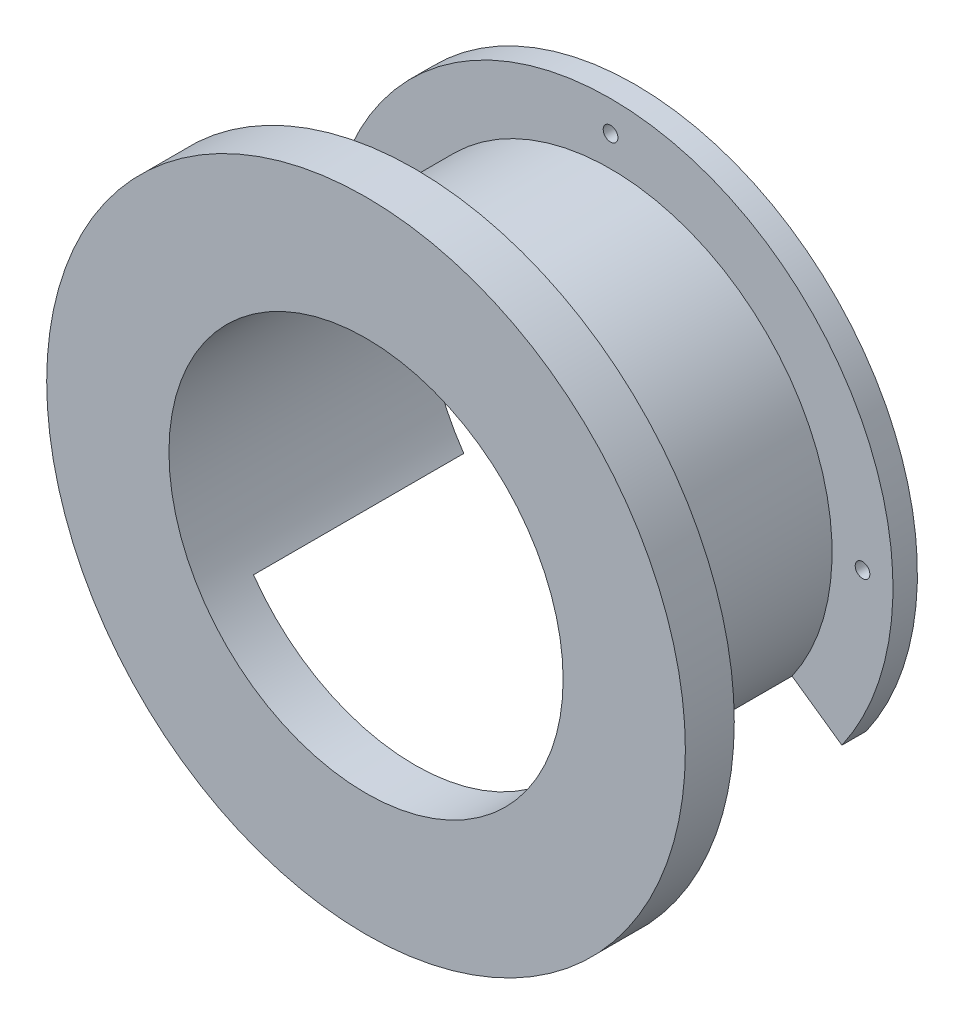
from build123d import *

# Parameters (mm, degrees)
BOSS_EXTRUDE1_DEPTH       = 10
BOSS_EXTRUDE2_DEPTH       = 100
BOSS_EXTRUDE2_DEPTH_BACK  = 6
BOSS_EXTRUDE3_DEPTH       = 20
F_6_0MM_DOWEL_HOLE4_D     = 6
F_6_0MM_DOWEL_HOLE4_DEPTH = 10


with BuildPart() as part:
    # Sketch1 → Boss-Extrude1 (new body)
    with BuildSketch(Plane.XY):
        with BuildLine():
            Line((-94.612061115, -66.248078399), (-74.215175213, -51.966025133))
            ThreePointArc((-74.215175213, -51.966025133), (0, 90.6), (74.215175213, -51.966025133))
            Line((74.215175213, -51.966025133), (94.612061115, -66.248078399))
            ThreePointArc((94.612061115, -66.248078399), (0, 115.5), (-94.612061115, -66.248078399))
        make_face()
    extrude(amount=BOSS_EXTRUDE1_DEPTH)

    # Sketch2 → Boss-Extrude2 (add, two sides)
    with BuildSketch(Plane.XY.offset(10)) as boss_extrude2_sk:
        with BuildLine():
            Line((-66.02365477, -46.23026077), (-74.215175213, -51.966025133))
            ThreePointArc((-74.215175213, -51.966025133), (0, 90.6), (74.215175213, -51.966025133))
            Line((74.215175213, -51.966025133), (66.02365477, -46.23026077))
            ThreePointArc((66.02365477, -46.23026077), (0, 80.6), (-66.02365477, -46.23026077))
        make_face()
    extrude(amount=BOSS_EXTRUDE2_DEPTH)
    extrude(boss_extrude2_sk.sketch, amount=-BOSS_EXTRUDE2_DEPTH_BACK)

    # Sketch3 → Boss-Extrude3 (add)
    with BuildSketch(Plane.XY.offset(110)):
        with BuildLine():
            ThreePointArc((-106.981256984, -74.909082587), (0, -130.6), (106.981256984, -74.909082587))
            ThreePointArc((106.981256984, -74.909082587), (0, 130.6), (-106.981256984, -74.909082587))
        make_face()
        with BuildLine():
            Line((-74.215175213, -51.966025133), (-66.02365477, -46.23026077))
            ThreePointArc((-66.02365477, -46.23026077), (0, -80.6), (66.02365477, -46.23026077))
            Line((66.02365477, -46.23026077), (74.215175213, -51.966025133))
            ThreePointArc((74.215175213, -51.966025133), (0, 90.6), (-74.215175213, -51.966025133))
        make_face(mode=Mode.SUBTRACT)
    extrude(amount=-BOSS_EXTRUDE3_DEPTH)

    # Ø6.0mm Dowel Hole4
    with Locations(Plane.XY.offset(10)):
        with Locations((-103.05, 0), (103.05, 0), (0, 103.05)):
            Hole(F_6_0MM_DOWEL_HOLE4_D / 2, depth=F_6_0MM_DOWEL_HOLE4_DEPTH)


solid = part.part
